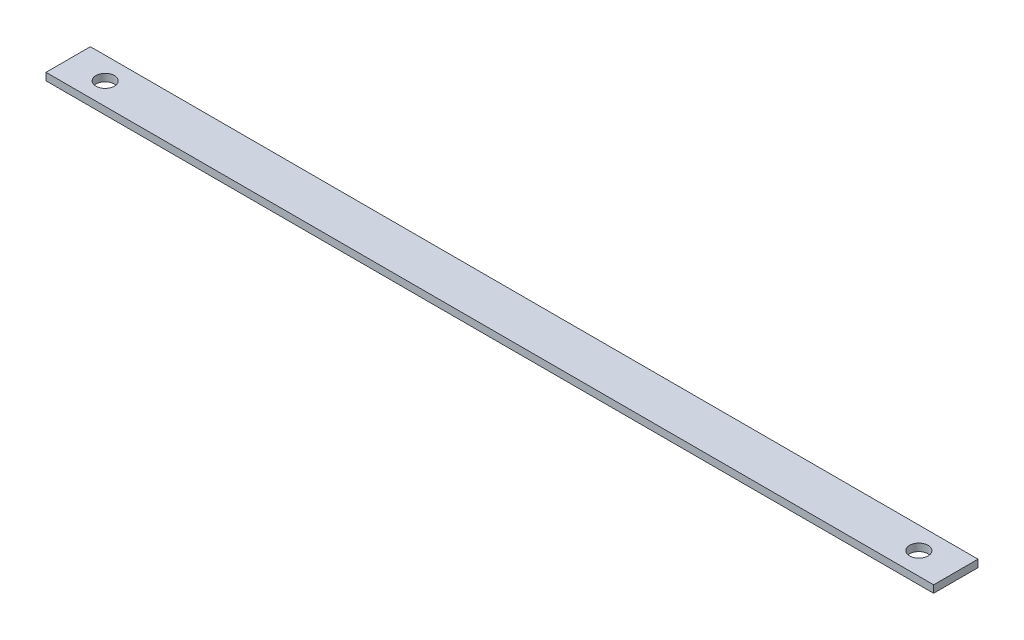
from build123d import *

# Parameters (mm, degrees)
SKETCH1_W                 = 240
SKETCH1_H                 = 12
BOSS_EXTRUDE1_DEPTH       = 2
F_5_0MM_DOWEL_HOLE1_D     = 5
F_5_0MM_DOWEL_HOLE1_DEPTH = 2


with BuildPart() as part:
    # Sketch1 → Boss-Extrude1 (new body)
    with BuildSketch(Plane(origin=(0, 0, 0), x_dir=(1, 0, 0), z_dir=(0, 1, 0))):
        Rectangle(SKETCH1_W, SKETCH1_H)
    extrude(amount=BOSS_EXTRUDE1_DEPTH)

    # Ø5.0mm Dowel Hole1
    with Locations(Plane(origin=(0, 2, 0), x_dir=(1, 0, 0), z_dir=(0, 1, 0))):
        with Locations((-110, 0), (110, 0)):
            Hole(F_5_0MM_DOWEL_HOLE1_D / 2, depth=F_5_0MM_DOWEL_HOLE1_DEPTH)


solid = part.part
